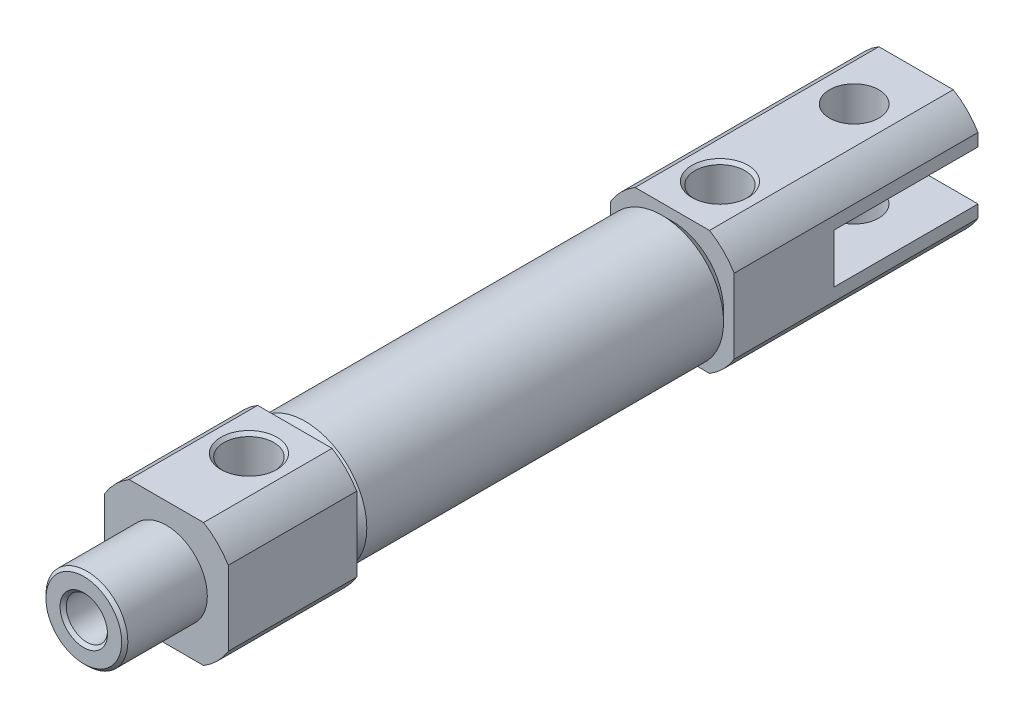
from build123d import *

# Parameters (mm, degrees)
SKETCH1_R                  = 5.97
BASE_EXTRUDE_DEPTH         = 18.285
BASE_EXTRUDE_DEPTH_BACK    = 18.285
TUBECHAMFER_SIZE           = 1
RODCOVER_DEPTH             = 12.45
HEADCOVER_DEPTH            = 23.62
SKETCH4_R                  = 3.96875
NOSETHREADS_DEPTH          = 8
SKETCH5_R                  = 2.415
FRONTPORT_DEPTH            = 7
RODBORE_START              = -47.585
SKETCH10_R                 = 2
RODBORE_DEPTH              = 47.585
SKETCH11_R                 = 5
STROKECHAMBER_DEPTH        = 17.7
SKETCH13_W                 = 13.97
SKETCH13_H                 = 4.78
D_CLEVISSIDECUT_DEPTH      = 7
D_CLEVISSIDECUT_DEPTH_BACK = 7
DETAILCHAMFER_SIZE         = 0.3
SKETCH12_R                 = 2.39
CUT_EXTRUDE1_DEPTH         = 7
CUT_EXTRUDE1_DEPTH_BACK    = 7


with BuildPart() as part:
    # Sketch1 → Base-Extrude (new body, two sides)
    with BuildSketch(Plane.XY) as base_extrude_sk:
        Circle(SKETCH1_R)
    extrude(amount=BASE_EXTRUDE_DEPTH)
    extrude(base_extrude_sk.sketch, amount=-BASE_EXTRUDE_DEPTH_BACK)

    # TubeChamfer
    tubechamfer_edges = [part.edges().sort_by_distance(p)[0] for p in [
        (-5.97, 0, -18.285),
        (-5.97, 0, 18.285),
    ]]
    chamfer(tubechamfer_edges, length=TUBECHAMFER_SIZE)

    # Sketch2 → RodCover (add)
    with BuildSketch(Plane.XY.offset(18.285)):
        with BuildLine():
            Line((-3.605551275, 6), (3.605551275, 6))
            ThreePointArc((3.605551275, 6), (4.949747468, 4.949747468), (6, 3.605551275))
            Line((6, 3.605551275), (6, -3.605551275))
            ThreePointArc((6, -3.605551275), (4.949747468, -4.949747468), (3.605551275, -6))
            Line((3.605551275, -6), (-3.605551275, -6))
            ThreePointArc((-3.605551275, -6), (-4.949747468, -4.949747468), (-6, -3.605551275))
            Line((-6, -3.605551275), (-6, 3.605551275))
            ThreePointArc((-6, 3.605551275), (-4.949747468, 4.949747468), (-3.605551275, 6))
        make_face()
    extrude(amount=RODCOVER_DEPTH)

    # Sketch3 → HeadCover (add)
    with BuildSketch(Plane(origin=(0, 0, -18.285), x_dir=(-1, 0, 0), z_dir=(0, 0, -1))):
        with BuildLine():
            Line((-3.605551275, 6), (3.605551275, 6))
            ThreePointArc((3.605551275, 6), (4.949747468, 4.949747468), (6, 3.605551275))
            Line((6, 3.605551275), (6, -3.605551275))
            ThreePointArc((6, -3.605551275), (4.949747468, -4.949747468), (3.605551275, -6))
            Line((3.605551275, -6), (-3.605551275, -6))
            ThreePointArc((-3.605551275, -6), (-4.949747468, -4.949747468), (-6, -3.605551275))
            Line((-6, -3.605551275), (-6, 3.605551275))
            ThreePointArc((-6, 3.605551275), (-4.949747468, 4.949747468), (-3.605551275, 6))
        make_face()
    extrude(amount=HEADCOVER_DEPTH)

    # Sketch4 → NoseThreads (add)
    with BuildSketch(Plane.XY.offset(30.735)):
        Circle(SKETCH4_R)
    extrude(amount=NOSETHREADS_DEPTH)

    # Sketch5 → FrontPort (cut, through all)
    with BuildSketch(Plane(origin=(0, 0, 0), x_dir=(1, 0, 0), z_dir=(0, 1, 0))):
        with Locations((0, -22.735)):
            Circle(SKETCH5_R)
    extrude(amount=FRONTPORT_DEPTH, mode=Mode.SUBTRACT)

    # Sketch7 → RearTopPort (revolve, cut)
    with BuildSketch(Plane(origin=(0, 0, 0), x_dir=(0, 0, -1), z_dir=(1, 0, 0))):
        Polygon((22.905, 0), (25.32, 0), (25.32, 5.7), (25.62, 6), (22.905, 6), align=None)
    revolve(axis=Axis((0, 0, -22.905), (0, 1, 0)), mode=Mode.SUBTRACT)

    # Sketch10 → RodBore (cut)
    with BuildSketch(Plane.XY.offset(38.735).offset(RODBORE_START)):
        Circle(SKETCH10_R)
    extrude(amount=RODBORE_DEPTH, mode=Mode.SUBTRACT)

    # Sketch11 → StrokeChamber (cut)
    with BuildSketch(Plane.XY.offset(-8.85)):
        Circle(SKETCH11_R)
    extrude(amount=STROKECHAMBER_DEPTH, mode=Mode.SUBTRACT)

    # Sketch13 → D-ClevisSideCut (cut, two sides)
    with BuildSketch(Plane(origin=(0, 0, 0), x_dir=(0, 0, -1), z_dir=(1, 0, 0))) as d_clevissidecut_sk:
        with Locations((34.92, 0)):
            Rectangle(SKETCH13_W, SKETCH13_H)
    extrude(amount=D_CLEVISSIDECUT_DEPTH, mode=Mode.SUBTRACT)
    extrude(d_clevissidecut_sk.sketch, amount=-D_CLEVISSIDECUT_DEPTH_BACK, mode=Mode.SUBTRACT)

    # DetailChamfer
    detailchamfer_edges = [part.edges().sort_by_distance(p)[0] for p in [
        (-3.96875, 0, 38.735),
        (-2.415, 6, 22.735),
        (-2, 0, 38.735),
    ]]
    chamfer(detailchamfer_edges, length=DETAILCHAMFER_SIZE)

    # Sketch12 → Cut-Extrude1 (cut, two sides)
    with BuildSketch(Plane(origin=(0, 0, 0), x_dir=(1, 0, 0), z_dir=(0, 1, 0))) as cut_extrude1_sk:
        with Locations((0, 35.905)):
            Circle(SKETCH12_R)
    extrude(amount=CUT_EXTRUDE1_DEPTH, mode=Mode.SUBTRACT)
    extrude(cut_extrude1_sk.sketch, amount=-CUT_EXTRUDE1_DEPTH_BACK, mode=Mode.SUBTRACT)


solid = part.part
